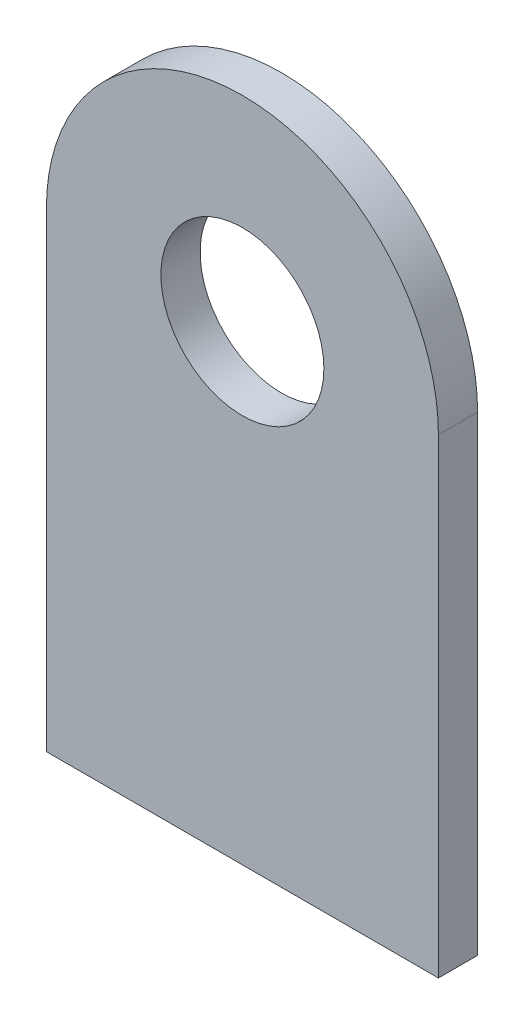
from build123d import *

# Parameters (mm, degrees)
BOSS_EXTRUDE1_DEPTH  = 1.5875
M6_CLEARANCE_HOLE1_D = 6.6
SKETCH5_W            = 15.875
SKETCH5_H            = 6.35
CUT_EXTRUDE2_DEPTH   = 2.5875


with BuildPart() as part:
    # Sketch1 → Boss-Extrude1 (new body)
    with BuildSketch(Plane.XY):
        with BuildLine():
            Line((7.9375, -25.4), (7.9375, 0))
            ThreePointArc((7.9375, 0), (0, 7.9375), (-7.9375, 0))
            Line((-7.9375, 0), (-7.9375, -25.4))
            Line((-7.9375, -25.4), (7.9375, -25.4))
        make_face()
    extrude(amount=BOSS_EXTRUDE1_DEPTH)

    # M6 Clearance Hole1 (through all)
    with Locations(Plane.XY.offset(1.5875)):
        with Locations((0, 0)):
            Hole(M6_CLEARANCE_HOLE1_D / 2)

    # Sketch5 → Cut-Extrude2 (cut, through all)
    with BuildSketch(Plane.XY.offset(1.5875)):
        with Locations((0, -22.225)):
            Rectangle(SKETCH5_W, SKETCH5_H)
    extrude(amount=-CUT_EXTRUDE2_DEPTH, mode=Mode.SUBTRACT)


solid = part.part
